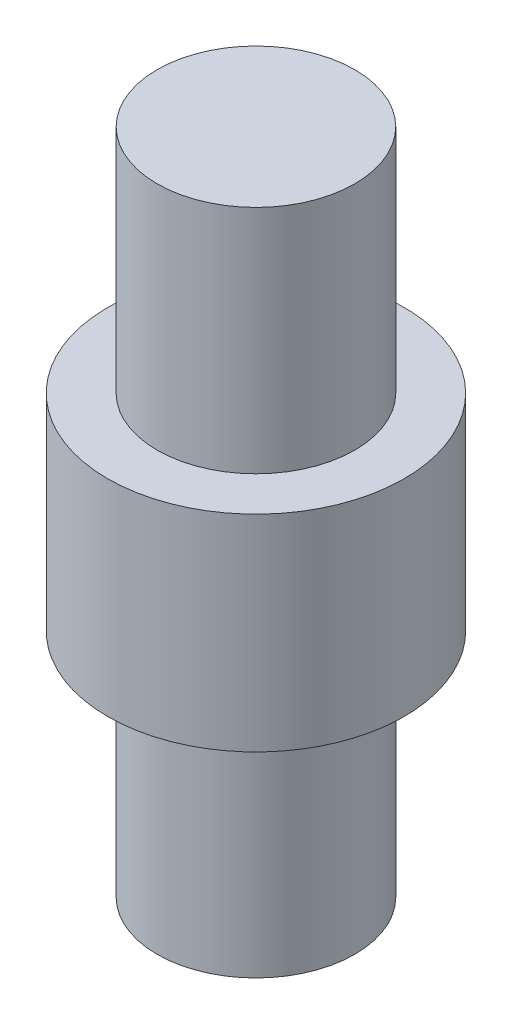
from build123d import *

# Parameters (mm, degrees)
SKETCH1_R           = 2.286
BOSS_EXTRUDE1_DEPTH = 1.5875
SKETCH2_R           = 1.524
BOSS_EXTRUDE2_DEPTH = 3.556


with BuildPart() as part:
    # Sketch1 → Boss-Extrude1 (new body, symmetric)
    with BuildSketch(Plane(origin=(0, 0, 0), x_dir=(1, 0, 0), z_dir=(0, 1, 0))):
        Circle(SKETCH1_R)
    extrude(amount=BOSS_EXTRUDE1_DEPTH, both=True)

    # Sketch2 → Boss-Extrude2 (add)
    with BuildSketch(Plane(origin=(0, -1.5875, 0), x_dir=(-1, 0, 0), z_dir=(0, -1, 0))):
        Circle(SKETCH2_R)
    boss_extrude2 = extrude(amount=BOSS_EXTRUDE2_DEPTH)

    # Mirror1: Boss-Extrude2 across plane
    add(boss_extrude2.mirror(Plane.ZX))


solid = part.part
